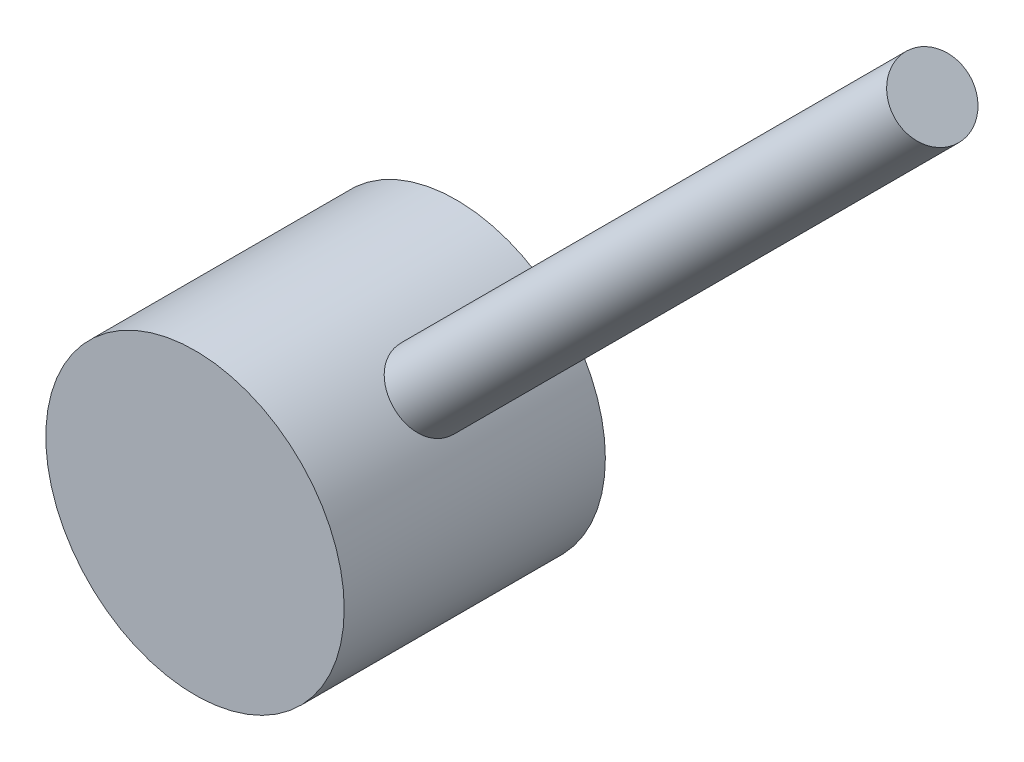
from build123d import *

# Parameters (mm, degrees)
SKETCH1_R                       = 4
CYLINDER_ON_WIRE_END_DEPTH      = 4.5
CYLINDER_ON_WIRE_END_DEPTH_BACK = 2.5
SKETCH4_R                       = 1
WIRE_2_DEPTH                    = 25


with BuildPart() as part:
    # Sketch1 → Cylinder on Wire end (new body, two sides)
    with BuildSketch(Plane.XY) as cylinder_on_wire_end_sk:
        Circle(SKETCH1_R)
    extrude(amount=CYLINDER_ON_WIRE_END_DEPTH)
    extrude(cylinder_on_wire_end_sk.sketch, amount=-CYLINDER_ON_WIRE_END_DEPTH_BACK)

    # Sketch4 → Wire 2 (add)
    with BuildSketch(Plane(origin=(-1.414213562, -1.414213562, 0), x_dir=(0.707106781, -0.707106781, 0), z_dir=(0.707106781, 0.707106781, 0))):
        with Locations((0, -1)):
            Circle(SKETCH4_R)
    extrude(amount=WIRE_2_DEPTH)


solid = part.part
